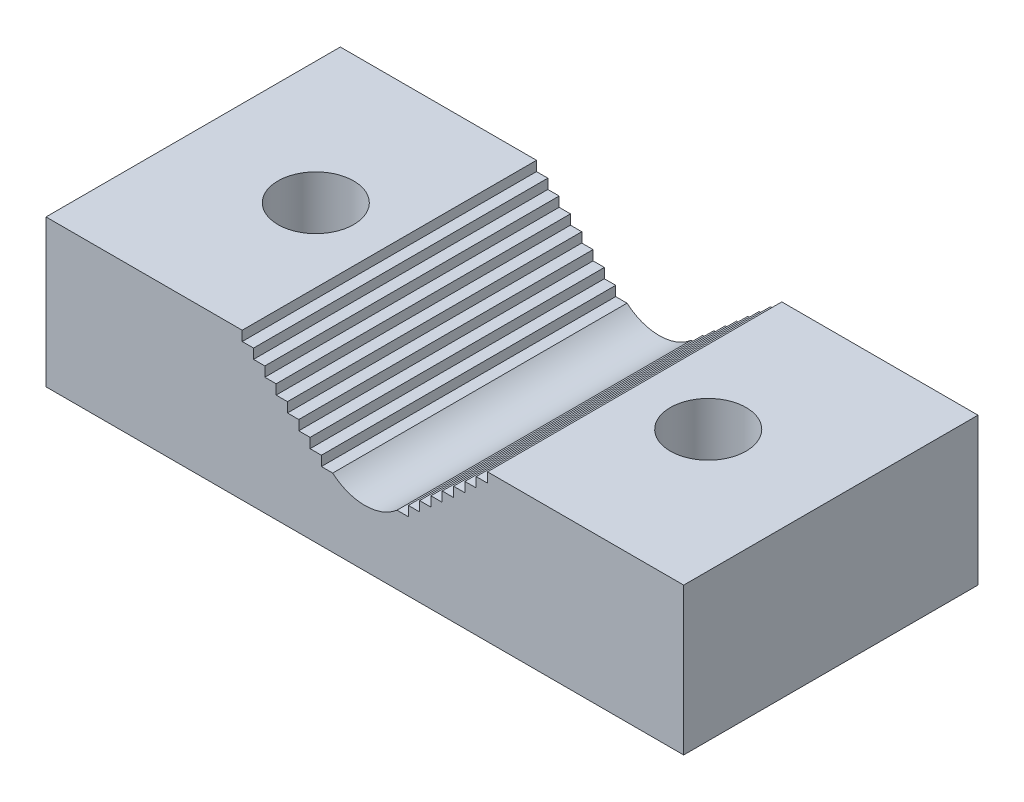
from build123d import *

# Parameters (mm, degrees)
SKETCH1_W               = 69.85
SKETCH1_H               = 19.05
BOSS_EXTRUDE1_DEPTH     = 38.1
CUT_EXTRUDE1_REACH      = 40.1
F_3_8_CLEARANCE_HOLE1_D = 9.8044
BOSS_EXTRUDE2_DEPTH     = 19.05


with BuildPart() as part:
    # Sketch1 → Boss-Extrude1 (new body)
    with BuildSketch(Plane.XY):
        with Locations((0, 9.525)):
            Rectangle(SKETCH1_W, SKETCH1_H)
    extrude(amount=-BOSS_EXTRUDE1_DEPTH)

    # Sketch2 → Cut-Extrude1 (cut, up to next)
    with BuildSketch(Plane.XY, mode=Mode.PRIVATE) as cut_extrude1_sk1:
        with BuildLine():
            Line((-15.875, 19.05), (0, 19.05))
            Line((0, 19.05), (15.875, 19.05))
            Line((15.875, 19.05), (15.875, 17.78))
            Line((15.875, 17.78), (14.410694861, 17.78))
            Line((14.410694861, 17.78), (14.410694861, 16.51))
            Line((14.410694861, 16.51), (12.946389723, 16.51))
            Line((12.946389723, 16.51), (12.946389723, 15.24))
            Line((12.946389723, 15.24), (11.482084584, 15.24))
            Line((11.482084584, 15.24), (11.482084584, 13.97))
            Line((11.482084584, 13.97), (10.017779445, 13.97))
            Line((10.017779445, 13.97), (10.017779445, 12.7))
            Line((10.017779445, 12.7), (8.553474306, 12.7))
            Line((8.553474306, 12.7), (8.553474306, 11.43))
            Line((8.553474306, 11.43), (7.089169168, 11.43))
            Line((7.089169168, 11.43), (7.089169168, 10.16))
            Line((7.089169168, 10.16), (5.624864029, 10.16))
            Line((5.624864029, 10.16), (5.624864029, 8.89))
            Line((5.624864029, 8.89), (4.16055889, 8.89))
            ThreePointArc((4.16055889, 8.89), (0, 7.337108475), (-4.16055889, 8.89))
            Line((-4.16055889, 8.89), (-5.624864029, 8.89))
            Line((-5.624864029, 8.89), (-5.624864029, 10.16))
            Line((-5.624864029, 10.16), (-7.089169168, 10.16))
            Line((-7.089169168, 10.16), (-7.089169168, 11.43))
            Line((-7.089169168, 11.43), (-8.553474306, 11.43))
            Line((-8.553474306, 11.43), (-8.553474306, 12.7))
            Line((-8.553474306, 12.7), (-10.017779445, 12.7))
            Line((-10.017779445, 12.7), (-10.017779445, 13.97))
            Line((-10.017779445, 13.97), (-11.482084584, 13.97))
            Line((-11.482084584, 13.97), (-11.482084584, 15.24))
            Line((-11.482084584, 15.24), (-12.946389723, 15.24))
            Line((-12.946389723, 15.24), (-12.946389723, 16.51))
            Line((-12.946389723, 16.51), (-14.410694861, 16.51))
            Line((-14.410694861, 16.51), (-14.410694861, 17.78))
            Line((-14.410694861, 17.78), (-15.875, 17.78))
            Line((-15.875, 17.78), (-15.875, 19.05))
        make_face()
    cut_extrude1_tool1 = extrude(cut_extrude1_sk1.sketch, amount=-CUT_EXTRUDE1_REACH, mode=Mode.PRIVATE) & part.part
    add(cut_extrude1_tool1.solids().sort_by_distance((0, 14.620592, 0))[0], mode=Mode.SUBTRACT)

    # 3/8 Clearance Hole1 (through all)
    with Locations(Plane(origin=(0, 19.05, 0), x_dir=(1, 0, 0), z_dir=(0, 1, 0))):
        with Locations((-25.4, 19.05), (25.4, 19.05)):
            Hole(F_3_8_CLEARANCE_HOLE1_D / 2)

    # Sketch7 → Boss-Extrude2 (add)
    with BuildSketch(Plane(origin=(0, 19.05, 0), x_dir=(1, 0, 0), z_dir=(0, 1, 0))):
        Polygon((-34.925, 38.1), (-41.275, 38.1), (-41.275, 0), (-32.371593609, 0), (-32.371593609, 38.1), align=None)
        Polygon((41.275, 0), (32.371593609, 0), (32.371593609, 38.1), (34.925, 38.1), (41.275, 38.1), align=None)
    extrude(amount=-BOSS_EXTRUDE2_DEPTH)


solid = part.part
